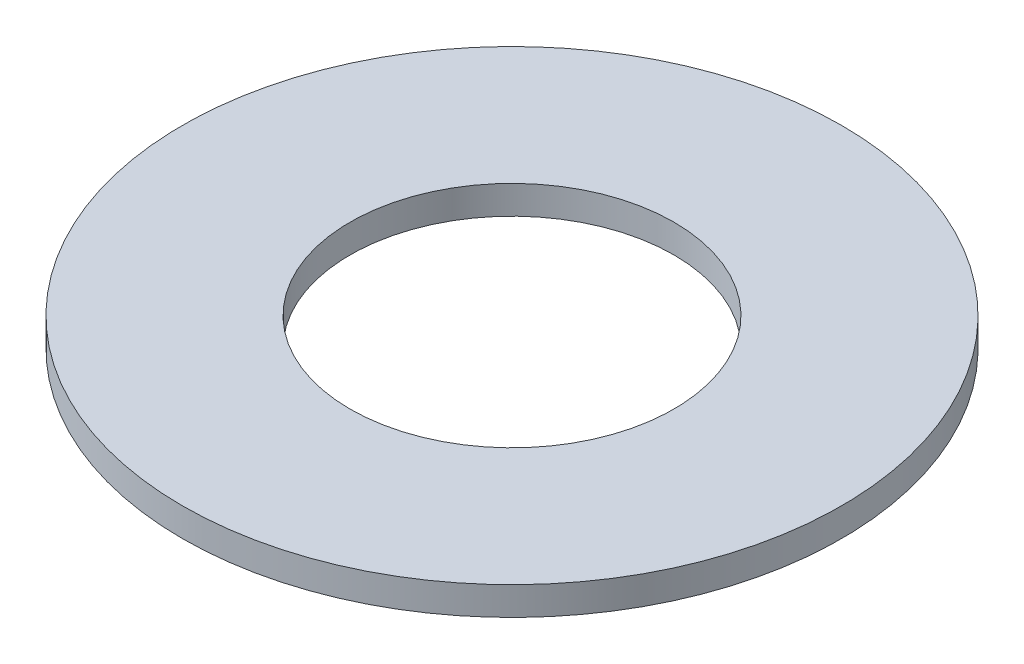
from build123d import *

# Parameters (mm, degrees)
SKETCH1_R           = 5.8
SKETCH1_R_2         = 2.85
BOSS_EXTRUDE2_DEPTH = 0.5


with BuildPart() as part:
    # Sketch1 → Boss-Extrude2 (new body)
    with BuildSketch(Plane(origin=(0, 0, 0), x_dir=(1, 0, 0), z_dir=(0, 1, 0))):
        Circle(SKETCH1_R)
        Circle(SKETCH1_R_2, mode=Mode.SUBTRACT)
    extrude(amount=BOSS_EXTRUDE2_DEPTH)


solid = part.part
